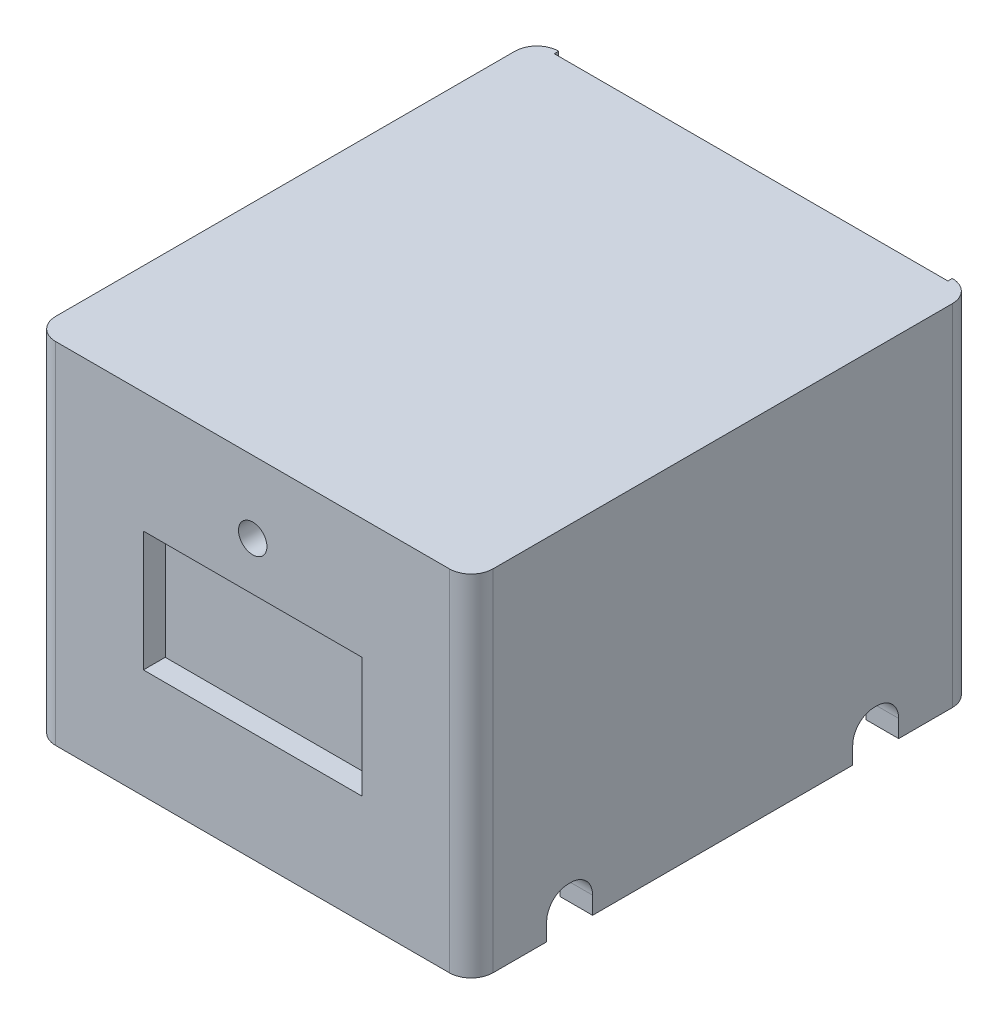
from build123d import *

# Parameters (mm, degrees)
ESQUISSE1_W             = 200
ESQUISSE1_H             = 160
BOSS_EXTRU_1_DEPTH      = 230
CONG_1_R                = 10
ESQUISSE2_W             = 170
ESQUISSE2_H             = 200
ENL_V_MAT_EXTRU_1_DEPTH = 20
ESQUISSE3_W             = 15
ESQUISSE3_H             = 21
ENL_V_MAT_EXTRU_2_DEPTH = 18
CONG_2_R                = 10
CONG_3_R                = 10
ESQUISSE6_W             = 180
ESQUISSE6_H             = 124
ENL_V_MAT_EXTRU_4_DEPTH = 130
ESQUISSE7_W             = 180
ESQUISSE7_H             = 2
ENL_V_MAT_EXTRU_5_DEPTH = 2
CONG_5_R                = 10
ESQUISSE8_R             = 6.5
ENL_V_MAT_EXTRU_6_DEPTH = 15
ESQUISSE9_W             = 100
ESQUISSE9_H             = 55
ENL_V_MAT_EXTRU_7_DEPTH = 10


with BuildPart() as part:
    # Esquisse1 → Boss.-Extru.1 (new body)
    with BuildSketch(Plane.XY):
        with Locations((100, 80)):
            Rectangle(ESQUISSE1_W, ESQUISSE1_H)
    extrude(amount=BOSS_EXTRU_1_DEPTH)

    # Congé1
    cong_1_edges = [part.edges().sort_by_distance(p)[0] for p in [
        (200, 80, 230),
        (0, 80, 230),
        (200, 80, 0),
        (0, 80, 0),
    ]]
    fillet(cong_1_edges, radius=CONG_1_R)

    # Esquisse2 → Enlèv. mat.-Extru.1 (cut)
    with BuildSketch(Plane.XZ):
        with Locations((100, 115)):
            Rectangle(ESQUISSE2_W, ESQUISSE2_H)
    extrude(amount=-ENL_V_MAT_EXTRU_1_DEPTH, mode=Mode.SUBTRACT)

    # Esquisse3 → Enlèv. mat.-Extru.2 (cut)
    with BuildSketch(Plane(origin=(0, 0, 0), x_dir=(-1, 0, 0), z_dir=(0, -1, 0))):
        with Locations((-7.5, -45.013282715)):
            Rectangle(ESQUISSE3_W, ESQUISSE3_H)
        with Locations((-192.5, -45.013282715)):
            Rectangle(ESQUISSE3_W, ESQUISSE3_H)
        with Locations((-192.5, -184.986717285)):
            Rectangle(ESQUISSE3_W, ESQUISSE3_H)
        with Locations((-7.5, -184.986717285)):
            Rectangle(ESQUISSE3_W, ESQUISSE3_H)
    extrude(amount=-ENL_V_MAT_EXTRU_2_DEPTH, mode=Mode.SUBTRACT)

    # Congé2
    cong_2_edges = [part.edges().sort_by_distance(p)[0] for p in [
        (192.5, 18, 34.513282715),
        (192.5, 18, 55.513282715),
    ]]
    fillet(cong_2_edges, radius=CONG_2_R)

    # Congé3
    cong_3_edges = [part.edges().sort_by_distance(p)[0] for p in [
        (7.5, 18, 34.513282715),
        (7.5, 18, 55.513282715),
    ]]
    fillet(cong_3_edges, radius=CONG_3_R)

    # Esquisse6 → Enlèv. mat.-Extru.4 (cut)
    with BuildSketch(Plane(origin=(0, 0, 0), x_dir=(-1, 0, 0), z_dir=(0, 0, -1))):
        with Locations((-100, 96)):
            Rectangle(ESQUISSE6_W, ESQUISSE6_H)
    extrude(amount=-ENL_V_MAT_EXTRU_4_DEPTH, mode=Mode.SUBTRACT)

    # Esquisse7 → Enlèv. mat.-Extru.5 (cut)
    with BuildSketch(Plane(origin=(0, 0, 0), x_dir=(-1, 0, 0), z_dir=(0, 0, -1))):
        with Locations((-100, 159)):
            Rectangle(ESQUISSE7_W, ESQUISSE7_H)
    extrude(amount=-ENL_V_MAT_EXTRU_5_DEPTH, mode=Mode.SUBTRACT)

    # Congé5
    cong_5_edges = [part.edges().sort_by_distance(p)[0] for p in [
        (7.5, 18, 195.486717285),
        (7.5, 18, 174.486717285),
        (192.5, 18, 195.486717285),
        (192.5, 18, 174.486717285),
    ]]
    fillet(cong_5_edges, radius=CONG_5_R)

    # Esquisse8 → Enlèv. mat.-Extru.6 (cut)
    with BuildSketch(Plane.XY.offset(230)):
        with Locations((100.086517688, 127.081087589)):
            Circle(ESQUISSE8_R)
    extrude(amount=-ENL_V_MAT_EXTRU_6_DEPTH, mode=Mode.SUBTRACT)

    # Esquisse9 → Enlèv. mat.-Extru.7 (cut)
    with BuildSketch(Plane.XY.offset(230)):
        with Locations((100.086517688, 77.5)):
            Rectangle(ESQUISSE9_W, ESQUISSE9_H)
    extrude(amount=-ENL_V_MAT_EXTRU_7_DEPTH, mode=Mode.SUBTRACT)


solid = part.part
